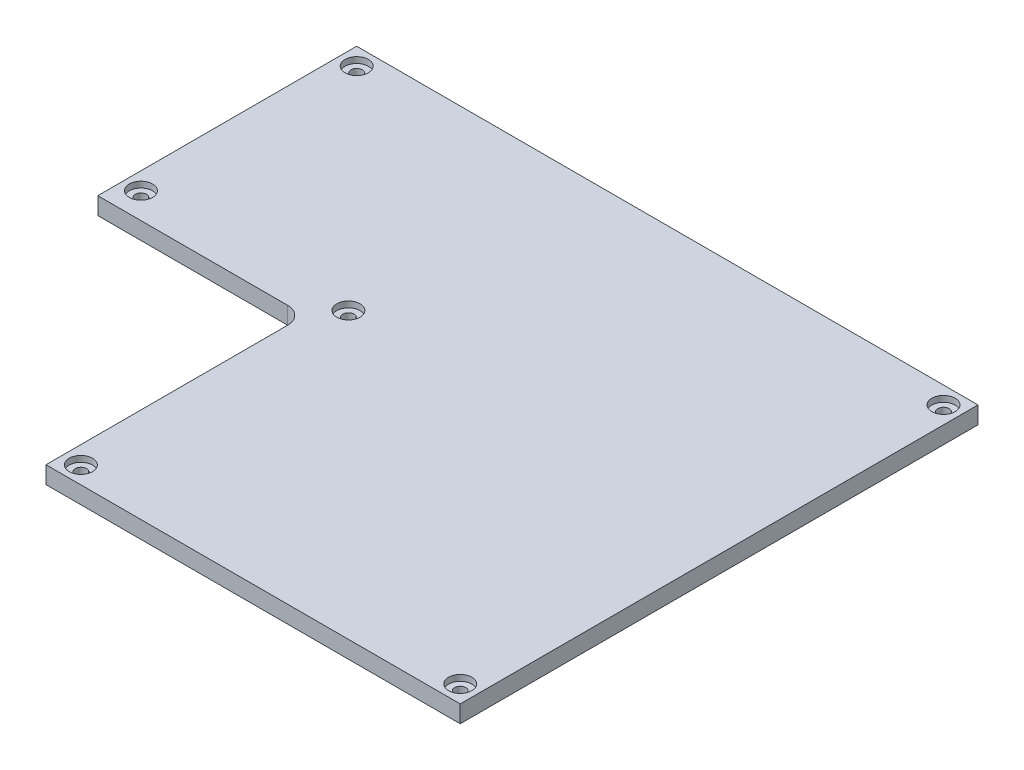
from build123d import *

# Parameters (mm, degrees)
BOSS_EXTRUDE1_DEPTH                                 = 5
CBORE_FOR_4_BINDING_HEAD_MACHINE_SCREW1_D           = 3.2639
CBORE_FOR_4_BINDING_HEAD_MACHINE_SCREW1_DEPTH       = 5
CBORE_FOR_4_BINDING_HEAD_MACHINE_SCREW1_CBORE_D     = 6.74624
CBORE_FOR_4_BINDING_HEAD_MACHINE_SCREW1_CBORE_DEPTH = 1.7272


with BuildPart() as part:
    # Sketch1 → Boss-Extrude1 (new body)
    with BuildSketch(Plane(origin=(0, 0, 0), x_dir=(1, 0, 0), z_dir=(0, 1, 0))):
        with BuildLine():
            Line((109.044117647, 56.029411765), (-70.955882353, 56.029411765))
            Line((-70.955882353, 56.029411765), (-70.955882353, -18.970588235))
            Line((-70.955882353, -18.970588235), (-15.955882353, -18.970588235))
            ThreePointArc((-15.955882353, -18.970588235), (-12.420348447, -20.435054329), (-10.955882353, -23.970588235))
            Line((-10.955882353, -23.970588235), (-10.955882353, -93.970588235))
            Line((-10.955882353, -93.970588235), (109.044117647, -93.970588235))
            Line((109.044117647, -93.970588235), (109.044117647, -18.970588235))
            Line((109.044117647, -18.970588235), (109.044117647, 56.029411765))
        make_face()
    extrude(amount=BOSS_EXTRUDE1_DEPTH)

    # CBORE for #4 Binding Head Machine Screw1
    with Locations(Plane(origin=(0, 5, 0), x_dir=(1, 0, 0), z_dir=(0, 1, 0))):
        with Locations((-65.955882353, 51.029411765), (-65.955882353, -11.470588235), (-5.845882353, -11.470588235), (-5.845882353, -88.970588235), (104.044117647, -88.970588235), (104.044117647, 51.029411765)):
            CounterBoreHole(CBORE_FOR_4_BINDING_HEAD_MACHINE_SCREW1_D / 2, CBORE_FOR_4_BINDING_HEAD_MACHINE_SCREW1_CBORE_D / 2, CBORE_FOR_4_BINDING_HEAD_MACHINE_SCREW1_CBORE_DEPTH, depth=CBORE_FOR_4_BINDING_HEAD_MACHINE_SCREW1_DEPTH)


solid = part.part
